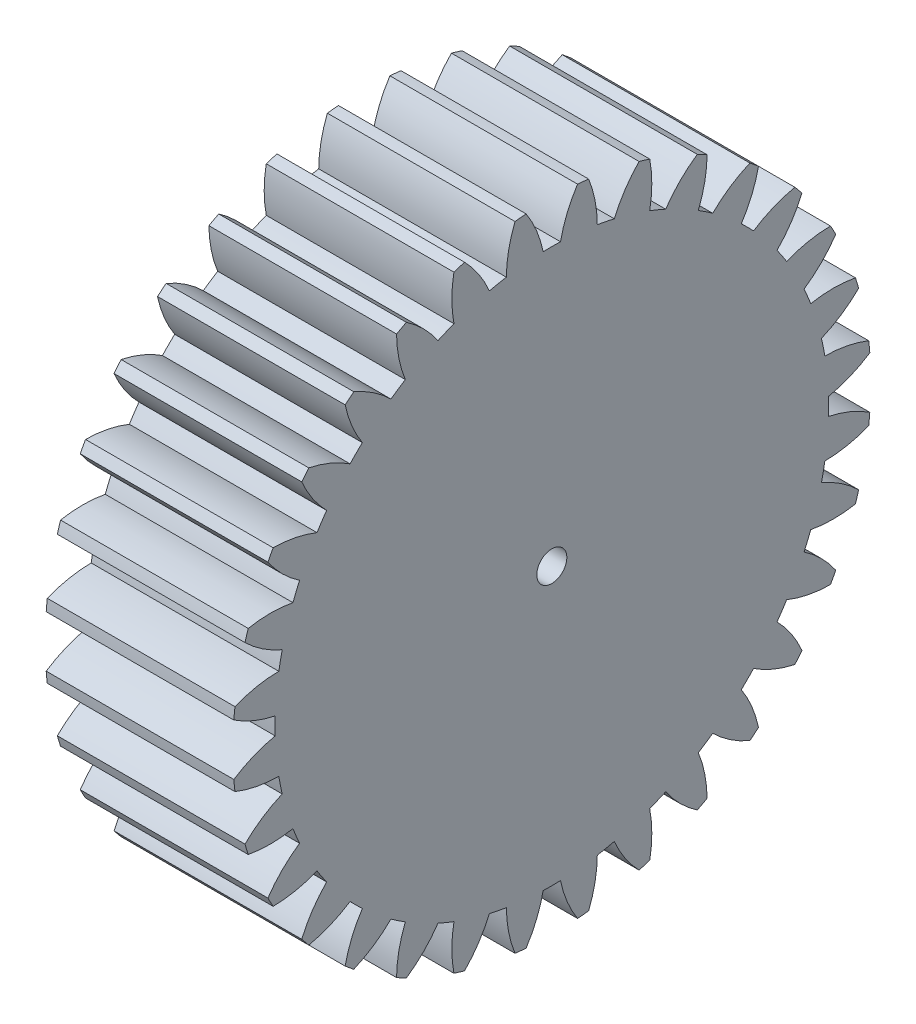
from build123d import *

# Parameters (mm, degrees)
BASPROSKE_W     = 5
BASPROSKE_H     = 8.5
TOOTHCUT_DEPTH  = 14.019216566
TEETHCUTS_COUNT = 32
TEETHCUTS_ANGLE = 348.75
BORSKE_R        = 0.4
BORE_DEPTH      = 50.0000508


with BuildPart() as part:
    # BasProSke → Base-Revolve (revolve)
    with BuildSketch(Plane(origin=(0, 0, 0), x_dir=(1, 0, 0), z_dir=(0, 1, 0)), mode=Mode.PRIVATE) as base_revolve_sk:
        with Locations((2.5, 4.25)):
            Rectangle(BASPROSKE_W, BASPROSKE_H)
    revolve(base_revolve_sk.sketch.rotate(Axis((-10, 0, 0), (1, 0, 0)), 180), axis=Axis((-10, 0, 0), (1, 0, 0)))

    # TooCutSke → ToothCut (cut, through all)
    with BuildSketch(Plane(origin=(0, 0, 0), x_dir=(0, 0, -1), z_dir=(1, 0, 0))):
        with BuildLine():
            ThreePointArc((0.230915662, 7.370383569), (0, 7.374), (-0.230915662, 7.370383569))
            ThreePointArc((-0.230915662, 7.370383569), (-0.411960263, 7.95607799), (-0.701370671, 8.496500712))
            ThreePointArc((-0.701370671, 8.496500712), (0, 8.5254), (0.701370671, 8.496500712))
            ThreePointArc((0.701370671, 8.496500712), (0.411960263, 7.95607799), (0.230915662, 7.370383569))
        make_face()
    toothcut = extrude(amount=TOOTHCUT_DEPTH, mode=Mode.SUBTRACT)

    # TeethCuts: ToothCut ×32 about axis
    teethcuts_axis = Axis((-10, 0, 0), (1, 0, 0))
    for i in range(1, TEETHCUTS_COUNT):
        add(toothcut.rotate(teethcuts_axis, i * TEETHCUTS_ANGLE / (TEETHCUTS_COUNT - 1)), mode=Mode.SUBTRACT)

    # BorSke → Bore (cut, symmetric)
    with BuildSketch(Plane(origin=(0, 0, 0), x_dir=(0, 0, -1), z_dir=(1, 0, 0))):
        with Locations(Location((0, 0, 0), (0, 0, 180))):
            Circle(BORSKE_R)
    extrude(amount=BORE_DEPTH, both=True, mode=Mode.SUBTRACT)


solid = part.part
